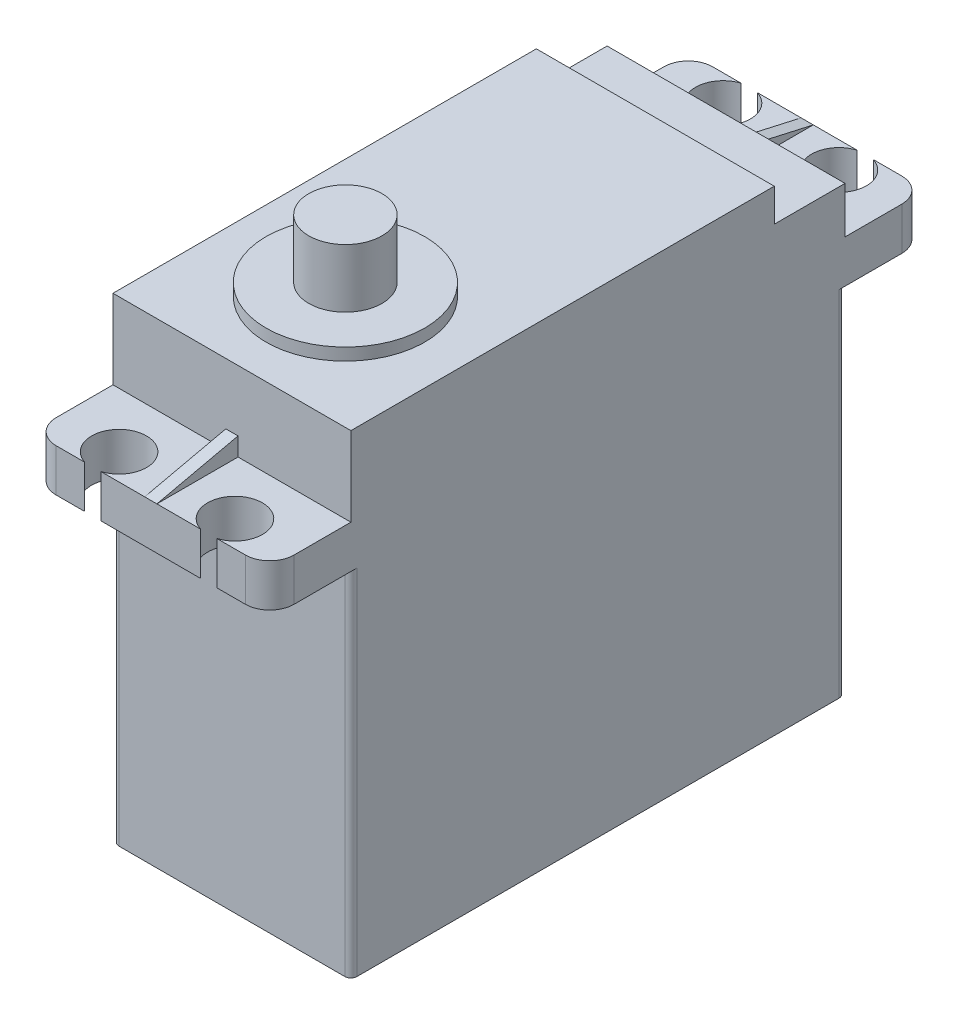
from build123d import *

# Parameters (mm, degrees)
MAIN_DEPTH          = 9.75
SKETCH4_R           = 6.5
BASECIRCLE_DEPTH    = 1
SKETCH5_R           = 3
GEAR_DEPTH          = 4.8
SKETCH9_R           = 2.25
FIXING_HOLE_DEPTH   = 19.05
FIXINGFILLET_R      = 2
REINFORCEMENT_DEPTH = 0.5
SERVOFILLET_R       = 0.5


with BuildPart() as part:
    # Sketch1 → Main (new body, symmetric)
    with BuildSketch(Plane(origin=(0, 0, 0), x_dir=(0, 0, -1), z_dir=(1, 0, 0))):
        Polygon((-40.5, 0), (0, 0), (0, 29), (6.65, 29), (6.65, 32.5), (0, 32.5), (0, 36.3), (-5.8, 36.3), (-5.8, 39), (-40.5, 39), (-40.5, 32.5), (-47.15, 32.5), (-47.15, 29), (-40.5, 29), align=None)
    extrude(amount=MAIN_DEPTH, both=True)

    # Sketch4 → BaseCircle (add)
    with BuildSketch(Plane(origin=(0, 39, 0), x_dir=(1, 0, 0), z_dir=(0, 1, 0))):
        with Locations((0, -31.2)):
            Circle(SKETCH4_R)
    extrude(amount=BASECIRCLE_DEPTH)

    # Sketch5 → Gear (add)
    with BuildSketch(Plane(origin=(0, 40, 0), x_dir=(1, 0, 0), z_dir=(0, 1, 0))):
        with Locations((0, -31.2)):
            Circle(SKETCH5_R)
    extrude(amount=GEAR_DEPTH)

    # Sketch9 → Fixing-Hole (cut)
    with BuildSketch(Plane(origin=(0, 32.5, 0), x_dir=(-1, 0, 0), z_dir=(0, 1, 0))):
        with Locations((-4.75, 45)):
            Circle(SKETCH9_R)
        with Locations((4.75, 45)):
            Circle(SKETCH9_R)
        with Locations((4.75, -4.5)):
            Circle(SKETCH9_R)
        with Locations((-4.75, -4.5)):
            Circle(SKETCH9_R)
    extrude(amount=-FIXING_HOLE_DEPTH, mode=Mode.SUBTRACT)

    # FixingFillet
    fixingfillet_edges = [part.edges().sort_by_distance(p)[0] for p in [
        (-9.75, 30.75, 47.15),
        (9.75, 30.75, -6.65),
        (-9.75, 30.75, -6.65),
        (9.75, 30.75, 47.15),
    ]]
    fillet(fixingfillet_edges, radius=FIXINGFILLET_R)

    # Esquisse1 → Reinforcement (add, symmetric)
    with BuildSketch(Plane(origin=(0, 0, 0), x_dir=(0, 0, -1), z_dir=(1, 0, 0))):
        Polygon((6.65, 32.5), (0, 34), (0, 32.5), align=None)
        Polygon((-47.15, 32.5), (-40.5, 32.5), (-40.5, 34), align=None)
    extrude(amount=REINFORCEMENT_DEPTH, both=True)

    # ServoFillet
    servofillet_edges = [part.edges().sort_by_distance(p)[0] for p in [
        (9.75, 14.5, 0),
        (-9.75, 14.5, 0),
        (-9.75, 14.5, 40.5),
        (9.75, 14.5, 40.5),
    ]]
    fillet(servofillet_edges, radius=SERVOFILLET_R)


solid = part.part
